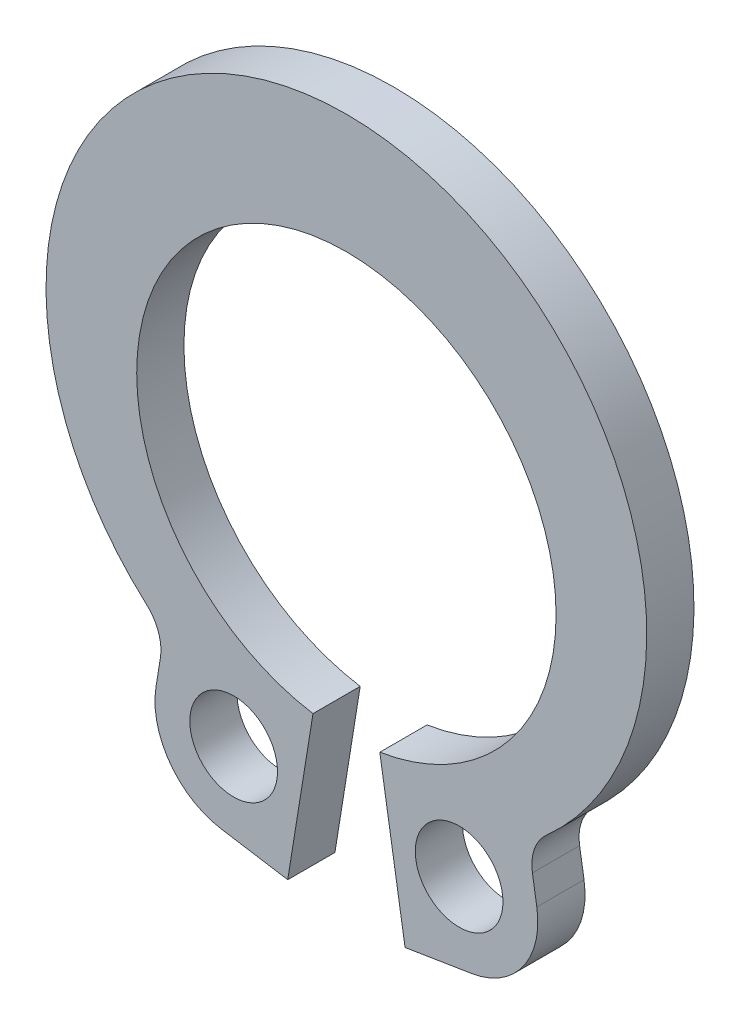
from build123d import *

# Parameters (mm, degrees)
BODY_DEPTH  = 1.0668
HOLSKE_R    = 0.9906
HOLES_DEPTH = 2.0668


with BuildPart() as part:
    # BodySke → Body (new body)
    with BuildSketch(Plane.XY):
        with BuildLine():
            Line((0.754834919, -4.676573602), (1.325514402, -8.212213698))
            Line((1.325514402, -8.212213698), (2.830042103, -7.969371365))
            ThreePointArc((2.830042103, -7.969371365), (3.988232781, -7.254926373), (4.302008364, -5.930772992))
            Line((4.302008364, -5.930772992), (4.202374684, -5.313493335))
            ThreePointArc((4.202374684, -5.313493335), (4.246706733, -4.824497903), (4.520407312, -4.416858533))
            ThreePointArc((4.520407312, -4.416858533), (0, 7.4295), (-4.520407312, -4.416858533))
            ThreePointArc((-4.520407312, -4.416858533), (-4.246706733, -4.824497903), (-4.202374684, -5.313493335))
            Line((-4.202374684, -5.313493335), (-4.302008364, -5.930772992))
            ThreePointArc((-4.302008364, -5.930772992), (-3.988232781, -7.254926373), (-2.830042103, -7.969371365))
            Line((-2.830042103, -7.969371365), (-1.325514402, -8.212213698))
            Line((-1.325514402, -8.212213698), (-0.754834919, -4.676573602))
            ThreePointArc((-0.754834919, -4.676573602), (0, 4.7371), (0.754834919, -4.676573602))
        make_face()
    extrude(amount=-BODY_DEPTH)

    # HolSke → Holes (cut, through all)
    with BuildSketch(Plane.XY):
        with Locations((2.546726047, -6.214089047)):
            Circle(HOLSKE_R)
        with Locations((-2.546726047, -6.214089047)):
            Circle(HOLSKE_R)
    extrude(amount=-HOLES_DEPTH, mode=Mode.SUBTRACT)


solid = part.part
